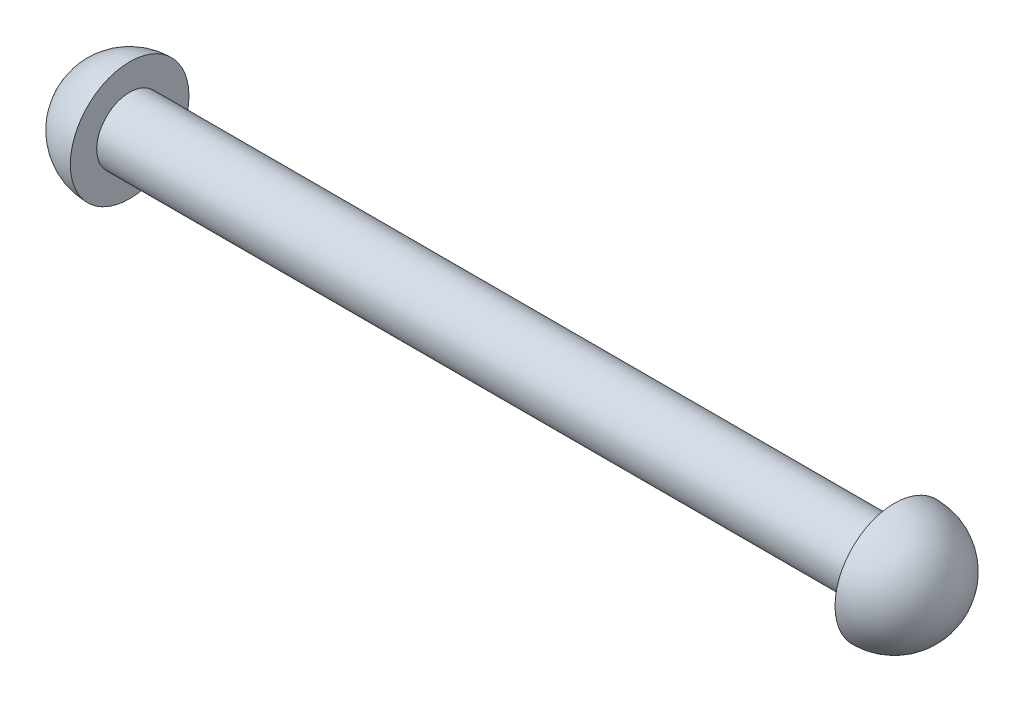
from build123d import *


with BuildPart() as part:
    # Sketch1 → Revolve1 (revolve)
    with BuildSketch(Plane.XY):
        with BuildLine():
            Line((5.715, 5.715), (5.715, 3.175))
            Line((5.715, 3.175), (79.375, 3.175))
            Line((79.375, 3.175), (79.375, 5.715))
            ThreePointArc((79.375, 5.715), (83.416115254, 4.041115254), (85.09, 0))
            Line((85.09, 0), (0, 0))
            ThreePointArc((0, 0), (1.673884746, 4.041115254), (5.715, 5.715))
        make_face()
    revolve(axis=Axis((0, 0, 0), (1, 0, 0)))


solid = part.part
